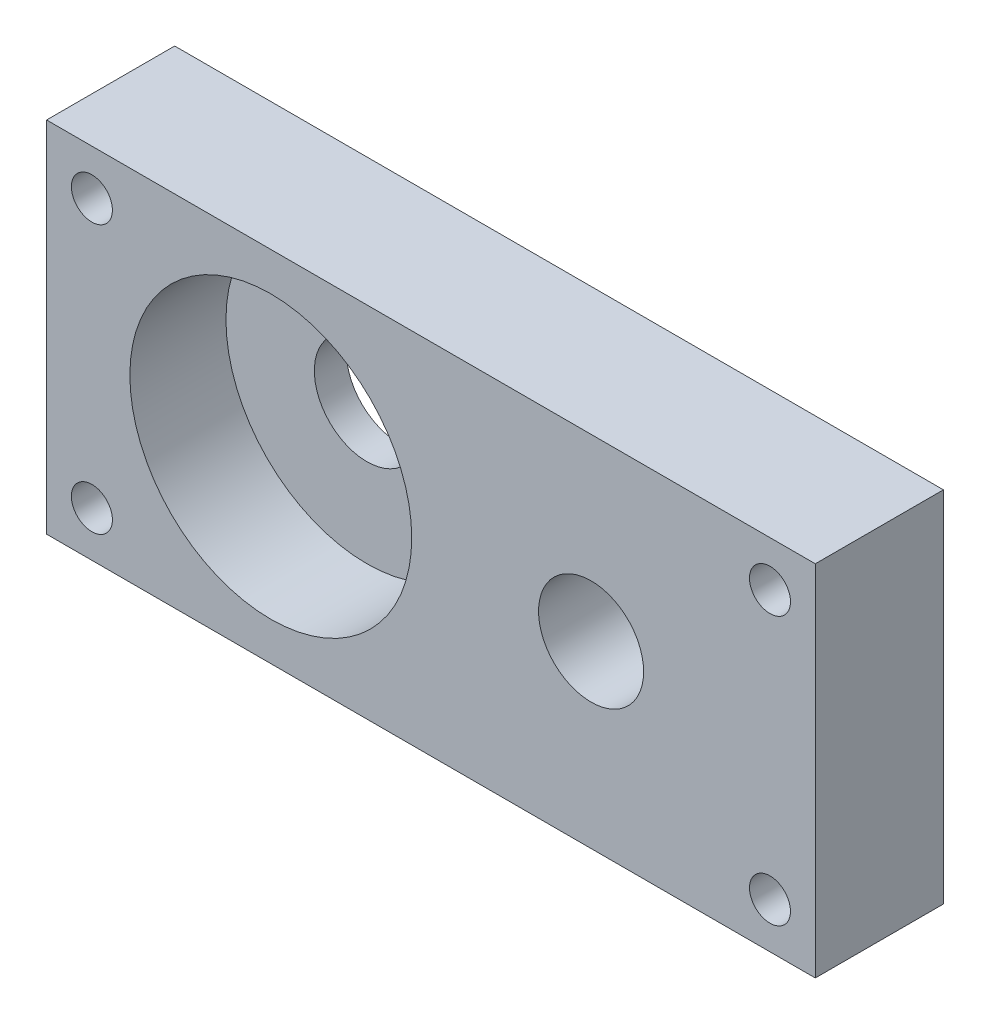
from build123d import *

# Parameters (mm, degrees)
SKETCH1_W           = 60
SKETCH1_H           = 28
SKETCH1_R           = 4.1
SKETCH1_R_2         = 1.6
BOSS_EXTRUDE1_DEPTH = 10
SKETCH2_R           = 11
CUT_EXTRUDE1_DEPTH  = 7.5


with BuildPart() as part:
    # Sketch1 → Boss-Extrude1 (new body)
    with BuildSketch(Plane.XY):
        Rectangle(SKETCH1_W, SKETCH1_H)
        with Locations((12.5, 0)):
            Circle(SKETCH1_R, mode=Mode.SUBTRACT)
        with Locations((-12.5, 0)):
            Circle(SKETCH1_R, mode=Mode.SUBTRACT)
        with Locations((-26.464466094, 10.464466094)):
            Circle(SKETCH1_R_2, mode=Mode.SUBTRACT)
        with Locations((-26.464466094, -10.464466094)):
            Circle(SKETCH1_R_2, mode=Mode.SUBTRACT)
        with Locations((26.464466094, -10.464466094)):
            Circle(SKETCH1_R_2, mode=Mode.SUBTRACT)
        with Locations((26.464466094, 10.464466094)):
            Circle(SKETCH1_R_2, mode=Mode.SUBTRACT)
    extrude(amount=BOSS_EXTRUDE1_DEPTH)

    # Sketch2 → Cut-Extrude1 (cut)
    with BuildSketch(Plane.XY.offset(10)):
        with Locations((-12.5, 0)):
            Circle(SKETCH2_R)
    extrude(amount=-CUT_EXTRUDE1_DEPTH, mode=Mode.SUBTRACT)


solid = part.part
